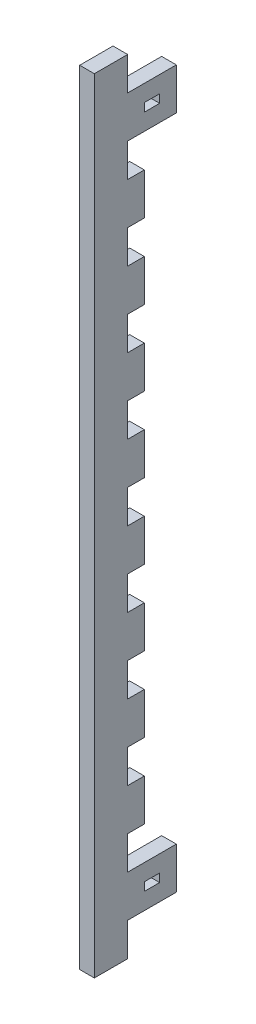
from build123d import *

# Parameters (mm, degrees)
BOSS_EXTRUDE1_DEPTH = 5.588
BOSS_EXTRUDE2_DEPTH = 5.588


with BuildPart() as part:
    # Sketch1 → Boss-Extrude1 (new body)
    with BuildSketch(Plane(origin=(0, 0, 0), x_dir=(0, 0, -1), z_dir=(1, 0, 0))):
        Polygon((3.175, 120.65), (9.525, 120.65), (9.525, 136.525), (3.175, 136.525), (3.175, 149.225), (-9.525, 149.225), (-9.525, -149.225), (3.175, -149.225), (3.175, -136.525), (9.525, -136.525), (9.525, -120.65), (3.175, -120.65), (3.175, -107.95), (9.525, -107.95), (9.525, -92.075), (3.175, -92.075), (3.175, -79.375), (9.525, -79.375), (9.525, -63.5), (3.175, -63.5), (3.175, -50.8), (9.525, -50.8), (9.525, -34.925), (3.175, -34.925), (3.175, -22.225), (9.525, -22.225), (9.525, -6.35), (3.175, -6.35), (3.175, 6.35), (9.525, 6.35), (9.525, 22.225), (3.175, 22.225), (3.175, 34.925), (9.525, 34.925), (9.525, 50.8), (3.175, 50.8), (3.175, 63.5), (9.525, 63.5), (9.525, 79.375), (3.175, 79.375), (3.175, 92.075), (9.525, 92.075), (9.525, 107.95), (3.175, 107.95), align=None)
    extrude(amount=BOSS_EXTRUDE1_DEPTH)

    # Sketch2 → Boss-Extrude2 (add)
    with BuildSketch(Plane(origin=(5.588, 0, 0), x_dir=(0, 0, -1), z_dir=(1, 0, 0))):
        Polygon((21.717, -120.65), (9.525, -120.65), (9.525, -127), (15.367, -127), (15.367, -130.175), (9.525, -130.175), (9.525, -136.525), (21.717, -136.525), align=None)
        Polygon((21.717, 136.525), (9.525, 136.525), (9.525, 130.175), (15.367, 130.175), (15.367, 127), (9.525, 127), (9.525, 120.65), (21.717, 120.65), align=None)
    extrude(amount=-BOSS_EXTRUDE2_DEPTH)


solid = part.part
